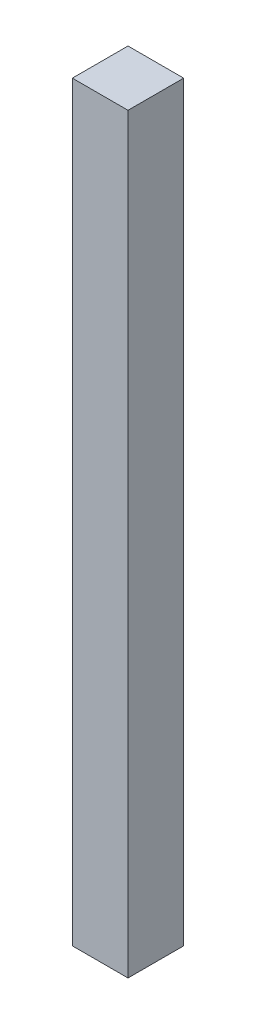
from build123d import *

# Parameters (mm, degrees)
SKETCH1_W           = 10
SKETCH1_H           = 10
BOSS_EXTRUDE1_DEPTH = 135


with BuildPart() as part:
    # Sketch1 → Boss-Extrude1 (new body)
    with BuildSketch(Plane(origin=(0, 0, 0), x_dir=(1, 0, 0), z_dir=(0, 1, 0))):
        with Locations((5, 5)):
            Rectangle(SKETCH1_W, SKETCH1_H)
    extrude(amount=BOSS_EXTRUDE1_DEPTH)


solid = part.part
